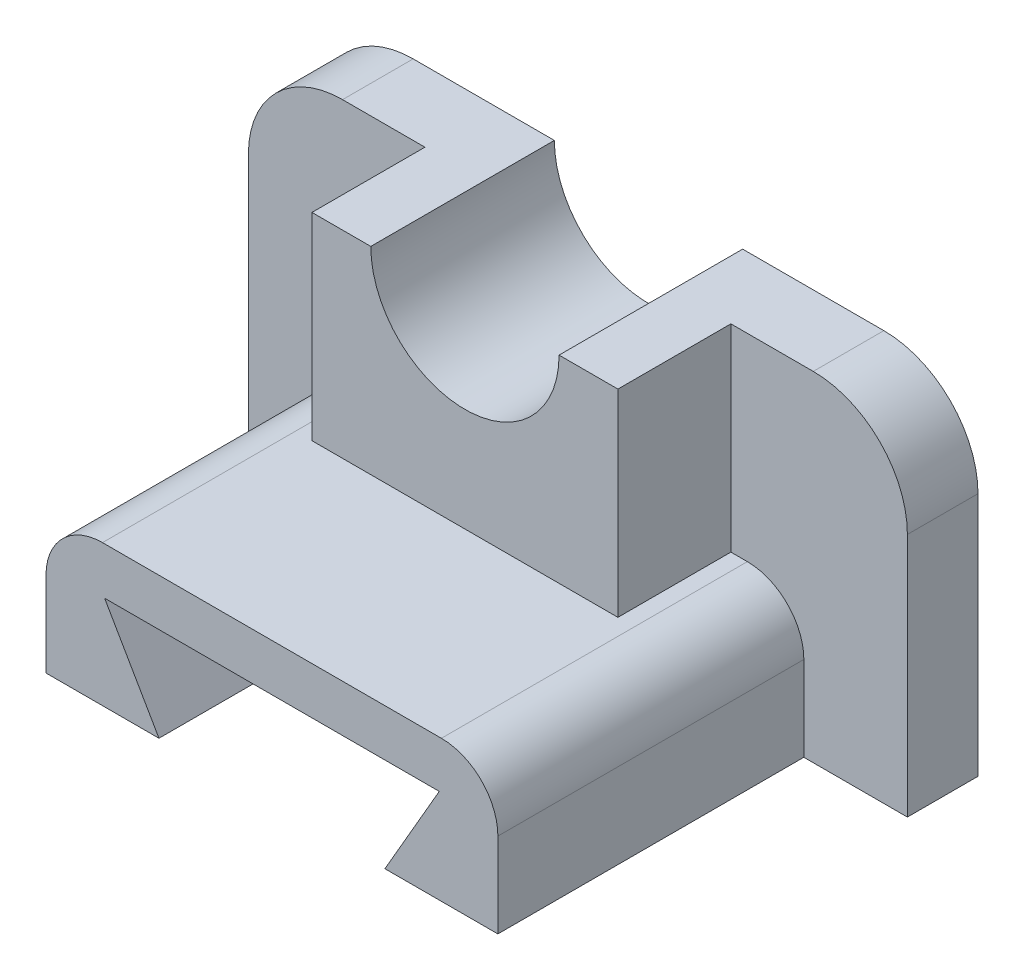
from build123d import *

# Parameters (mm, degrees)
IZIM1_W                     = 65
IZIM1_H                     = 42
Y_KSEKLIK_EKSTR_ZYON1_DEPTH = 80
IZIM3_R                     = 20
KES_EKSTR_ZYON1_DEPTH       = 81
KES_EKSTR_ZYON2_DEPTH       = 41
KES_EKSTR_ZYON5_DEPTH       = 65
KES_EKSTR_ZYON6_DEPTH       = 156
KES_EKSTR_ZYON6_DEPTH_BACK  = 1


with BuildPart() as part:
    # Çizim1 → Yükseklik-Ekstrüzyon1 (new body)
    with BuildSketch(Plane.XY):
        with BuildLine():
            Line((-120, -72), (-100, -72))
            Line((-100, -72), (0, -72))
            Line((0, -72), (20, -72))
            Line((20, -72), (20, -20))
            ThreePointArc((20, -20), (14.142135624, -5.857864376), (0, 0))
            Line((0, 0), (-17.5, 0))
            Line((-17.5, 0), (-17.5, -42))
            Line((-17.5, -42), (-82.5, -42))
            Line((-82.5, -42), (-82.5, 0))
            Line((-82.5, 0), (-100, 0))
            ThreePointArc((-100, 0), (-114.142135624, -5.857864376), (-120, -20))
            Line((-120, -20), (-120, -72))
        make_face()
        with Locations((-50, -21)):
            Rectangle(IZIM1_W, IZIM1_H)
    extrude(amount=Y_KSEKLIK_EKSTR_ZYON1_DEPTH)

    # Çizim3 → Kes-Ekstrüzyon1 (cut, through all)
    with BuildSketch(Plane.XY.offset(80)):
        with Locations((-50, 0)):
            Circle(IZIM3_R)
    extrude(amount=-KES_EKSTR_ZYON1_DEPTH, mode=Mode.SUBTRACT)

    # Çizim4 → Kes-Ekstrüzyon2 (cut)
    with BuildSketch(Plane.XY.offset(80)):
        with BuildLine():
            ThreePointArc((-30, 0), (-50, -20), (-70, 0))
            Line((-70, 0), (-82.5, 0))
            Line((-82.5, 0), (-82.5, -42))
            Line((-82.5, -42), (-17.5, -42))
            Line((-17.5, -42), (-17.5, 0))
            Line((-17.5, 0), (-30, 0))
        make_face()
    extrude(amount=-KES_EKSTR_ZYON2_DEPTH, mode=Mode.SUBTRACT)

    # Çizim5 → Kes-Ekstrüzyon5 (cut)
    with BuildSketch(Plane.XY.offset(80)):
        with BuildLine():
            Line((-120, -20), (-120, -72))
            Line((-120, -72), (-98, -72))
            Line((-98, -72), (-98, -54))
            ThreePointArc((-98, -54), (-94.485281374, -45.514718626), (-86, -42))
            Line((-86, -42), (-82.5, -42))
            Line((-82.5, -42), (-82.5, 0))
            Line((-82.5, 0), (-100, 0))
            ThreePointArc((-100, 0), (-114.142135624, -5.857864376), (-120, -20))
        make_face()
        with BuildLine():
            Line((-2, -54), (-2, -72))
            Line((-2, -72), (20, -72))
            Line((20, -72), (20, -20))
            ThreePointArc((20, -20), (14.142135624, -5.857864376), (0, 0))
            Line((0, 0), (-17.5, 0))
            Line((-17.5, 0), (-17.5, -42))
            Line((-17.5, -42), (-14, -42))
            ThreePointArc((-14, -42), (-5.514718626, -45.514718626), (-2, -54))
        make_face()
        Polygon((-85.547005384, -52), (-74, -72), (-26, -72), (-14.452994616, -52), align=None)
    extrude(amount=-KES_EKSTR_ZYON5_DEPTH, mode=Mode.SUBTRACT)

    # Çizim16 → Kes-Ekstrüzyon6 (cut, two sides)
    with BuildSketch(Plane.XY) as kes_ekstr_zyon6_sk:
        Polygon((-74, -72), (-85.547005384, -52), (-14.452994616, -52), (-26, -72), align=None)
    extrude(amount=KES_EKSTR_ZYON6_DEPTH, mode=Mode.SUBTRACT)
    extrude(kes_ekstr_zyon6_sk.sketch, amount=-KES_EKSTR_ZYON6_DEPTH_BACK, mode=Mode.SUBTRACT)


solid = part.part
